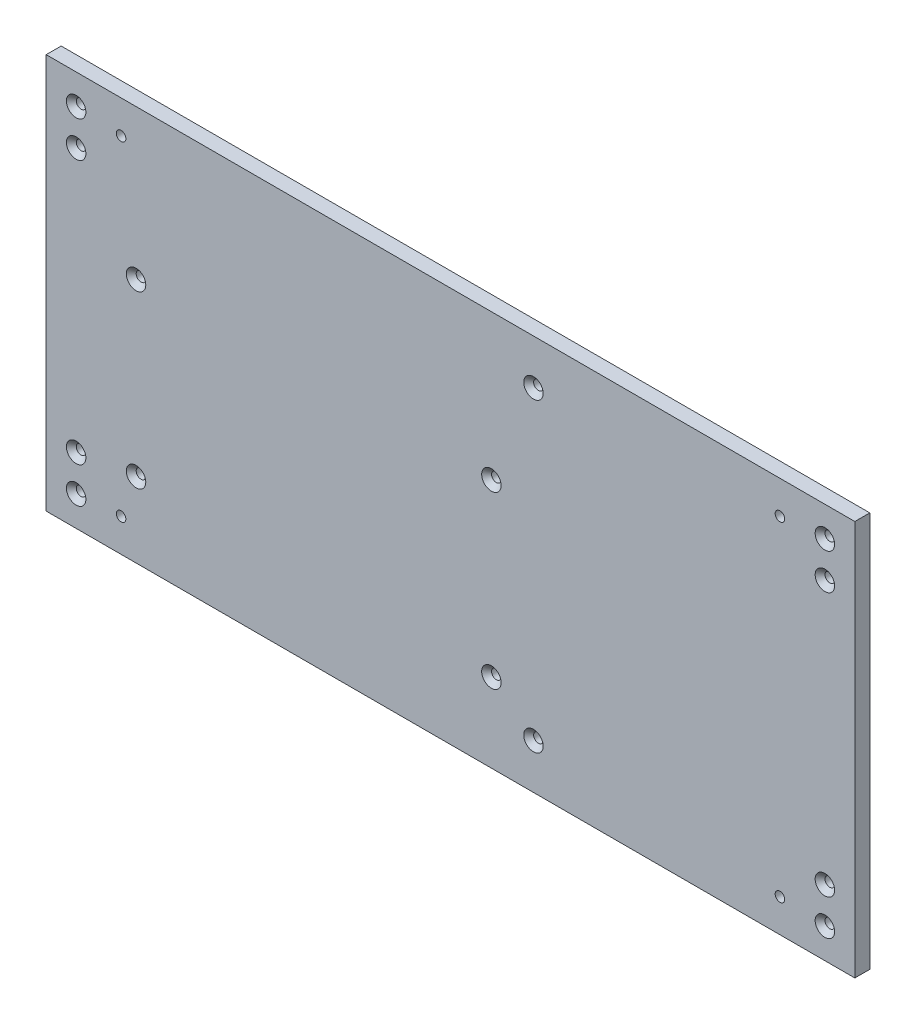
from build123d import *

# Parameters (mm, degrees)
SKETCH1_W                            = 270
SKETCH1_H                            = 132
SHEET_DEPTH                          = 2.5
F_3_2_3_2_WALLMOUNTHOLES_D           = 3.2
F_3_2_3_2_WALLMOUNTHOLES_CSINK_D     = 6.5
F_3_2_3_2_WALLMOUNTHOLES_CSINK_ANGLE = 90
F_3_2_3_2_FEETMOUNTHOLES_D           = 3.2
F_3_2_3_2_PSUHOLES_D                 = 3.2
F_3_2_3_2_PSUHOLES_CSINK_D           = 6.5
F_3_2_3_2_PSUHOLES_CSINK_ANGLE       = 90


with BuildPart() as part:
    # Sketch1 → Sheet (new body, symmetric)
    with BuildSketch(Plane.XY):
        Rectangle(SKETCH1_W, SKETCH1_H)
    extrude(amount=SHEET_DEPTH, both=True)

    # Ø3.2 (3.2) WallMountHoles (through all)
    with Locations(Plane.XY.offset(2.5)):
        with Locations((-125, 56), (-125, 44), (-125, -44), (-125, -56), (125, -56), (125, -44), (125, 44), (125, 56), (27.7, -51), (27.7, 51)):
            CounterSinkHole(F_3_2_3_2_WALLMOUNTHOLES_D / 2, F_3_2_3_2_WALLMOUNTHOLES_CSINK_D / 2, counter_sink_angle=F_3_2_3_2_WALLMOUNTHOLES_CSINK_ANGLE)

    # Ø3.2 (3.2) FeetMountHoles (through all)
    with Locations(Plane.XY.offset(2.5)):
        with Locations((110, 55), (-110, 55), (-110, -55), (110, -55)):
            Hole(F_3_2_3_2_FEETMOUNTHOLES_D / 2)

    # Ø3.2 (3.2) PSUHoles (through all)
    with Locations(Plane.XY.offset(2.5)):
        with Locations((13.65, -39.65), (-105, 16), (13.65, 17.35), (-105, -41)):
            CounterSinkHole(F_3_2_3_2_PSUHOLES_D / 2, F_3_2_3_2_PSUHOLES_CSINK_D / 2, counter_sink_angle=F_3_2_3_2_PSUHOLES_CSINK_ANGLE)


solid = part.part
